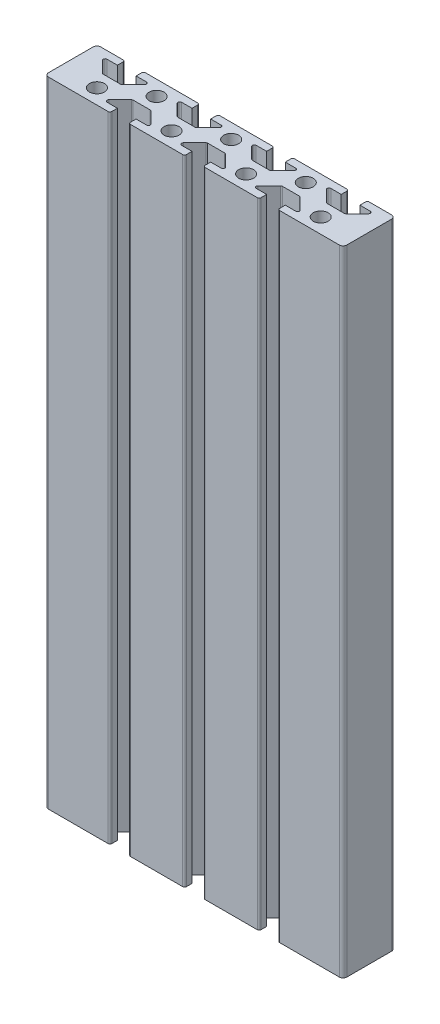
from build123d import *

# Parameters (mm, degrees)
SKETCH1_R           = 2
BOSS_EXTRUDE1_DEPTH = 170
FILLET1_R           = 0.5
FILLET2_R           = 0.5
FILLET3_R           = 1
SKETCH2_R           = 2.5
CUT_EXTRUDE2_DEPTH  = 230
SKETCH3_R           = 5.5
CUT_EXTRUDE3_DEPTH  = 7
SKETCH4_R           = 2.5
CUT_EXTRUDE4_DEPTH  = 7
SKETCH5_R           = 5.5
CUT_EXTRUDE5_DEPTH  = 7


with BuildPart() as part:
    # Sketch1 → Boss-Extrude1 (new body)
    with BuildSketch(Plane(origin=(0, 0, 0), x_dir=(1, 0, 0), z_dir=(0, 1, 0))):
        Polygon((67.5, 8), (63.5, 12), (67.5, 12), (67.5, 14), (52.5, 14), (52.5, 12), (56.5, 12), (52.5, 8), (47.5, 8), (43.5, 12), (47.5, 12), (47.5, 14), (32.5, 14), (32.5, 12), (36.5, 12), (32.5, 8), (27.5, 8), (23.5, 12), (27.5, 12), (27.5, 14), (12.5, 14), (12.5, 12), (16.5, 12), (12.5, 8), (7.5, 8), (3.5, 12), (7.5, 12), (7.5, 14), (0, 14), (0, 0), (17.5, 0), (17.5, 2), (13.5, 2), (17.5, 6), (22.5, 6), (26.5, 2), (22.5, 2), (22.5, 0), (37.5, 0), (37.5, 2), (33.5, 2), (37.5, 6), (42.5, 6), (46.5, 2), (42.5, 2), (42.5, 0), (57.5, 0), (57.5, 2), (53.5, 2), (57.5, 6), (62.5, 6), (66.5, 2), (62.5, 2), (62.5, 0), (80, 0), (80, 14), (72.5, 14), (72.5, 12), (76.5, 12), (72.5, 8), align=None)
        with Locations((10, 4)):
            Circle(SKETCH1_R, mode=Mode.SUBTRACT)
        with Locations((30, 4)):
            Circle(SKETCH1_R, mode=Mode.SUBTRACT)
        with Locations((50, 4)):
            Circle(SKETCH1_R, mode=Mode.SUBTRACT)
        with Locations((70, 4)):
            Circle(SKETCH1_R, mode=Mode.SUBTRACT)
        with Locations((20, 10)):
            Circle(SKETCH1_R, mode=Mode.SUBTRACT)
        with Locations((40, 10)):
            Circle(SKETCH1_R, mode=Mode.SUBTRACT)
        with Locations((60, 10)):
            Circle(SKETCH1_R, mode=Mode.SUBTRACT)
    extrude(amount=BOSS_EXTRUDE1_DEPTH)

    # Fillet1
    fillet1_edges = [part.edges().sort_by_distance(p)[0] for p in [
        (7.5, 85, -14),
        (3.5, 85, -12),
        (7.5, 85, -8),
        (12.5, 85, -8),
        (16.5, 85, -12),
        (12.5, 85, -14),
        (27.5, 85, -14),
        (23.5, 85, -12),
        (27.5, 85, -8),
        (32.5, 85, -8),
        (36.5, 85, -12),
        (32.5, 85, -14),
        (47.5, 85, -14),
        (43.5, 85, -12),
        (47.5, 85, -8),
        (52.5, 85, -8),
        (56.5, 85, -12),
        (52.5, 85, -14),
        (67.5, 85, -14),
        (63.5, 85, -12),
        (67.5, 85, -8),
        (72.5, 85, -8),
        (76.5, 85, -12),
        (72.5, 85, -14),
    ]]
    fillet(fillet1_edges, radius=FILLET1_R)

    # Fillet2
    fillet2_edges = [part.edges().sort_by_distance(p)[0] for p in [
        (26.5, 85, -2),
        (22.5, 85, -6),
        (17.5, 85, -6),
        (13.5, 85, -2),
        (17.5, 85, 0),
        (62.5, 85, 0),
        (66.5, 85, -2),
        (62.5, 85, -6),
        (57.5, 85, -6),
        (53.5, 85, -2),
        (57.5, 85, 0),
        (42.5, 85, 0),
        (46.5, 85, -2),
        (42.5, 85, -6),
        (37.5, 85, -6),
        (33.5, 85, -2),
        (37.5, 85, 0),
        (22.5, 85, 0),
    ]]
    fillet(fillet2_edges, radius=FILLET2_R)

    # Fillet3
    fillet3_edges = [part.edges().sort_by_distance(p)[0] for p in [
        (0, 85, 0),
        (0, 85, -14),
        (80, 85, -14),
        (80, 85, 0),
    ]]
    fillet(fillet3_edges, radius=FILLET3_R)

    # Sketch2 → Cut-Extrude2 (cut)
    with BuildSketch(Plane(origin=(0, 0, -14), x_dir=(-1, 0, 0), z_dir=(0, 0, -1))):
        with Locations((-40, 10)):
            Circle(SKETCH2_R)
    extrude(amount=-CUT_EXTRUDE2_DEPTH, mode=Mode.SUBTRACT)

    # Sketch3 → Cut-Extrude3 (cut)
    with BuildSketch(Plane(origin=(0, 0, -14), x_dir=(-1, 0, 0), z_dir=(0, 0, -1))):
        with Locations((-40, 10)):
            Circle(SKETCH3_R)
    extrude(amount=-CUT_EXTRUDE3_DEPTH, mode=Mode.SUBTRACT)

    # Sketch4 → Cut-Extrude4 (cut)
    with BuildSketch(Plane(origin=(0, 0, -14), x_dir=(-1, 0, 0), z_dir=(0, 0, -1))):
        with Locations((-40, 160)):
            Circle(SKETCH4_R)
    extrude(amount=-CUT_EXTRUDE4_DEPTH, mode=Mode.SUBTRACT)

    # Sketch5 → Cut-Extrude5 (cut)
    with BuildSketch(Plane(origin=(0, 0, -14), x_dir=(-1, 0, 0), z_dir=(0, 0, -1))):
        with Locations((-40, 160)):
            Circle(SKETCH5_R)
    extrude(amount=-CUT_EXTRUDE5_DEPTH, mode=Mode.SUBTRACT)


solid = part.part
